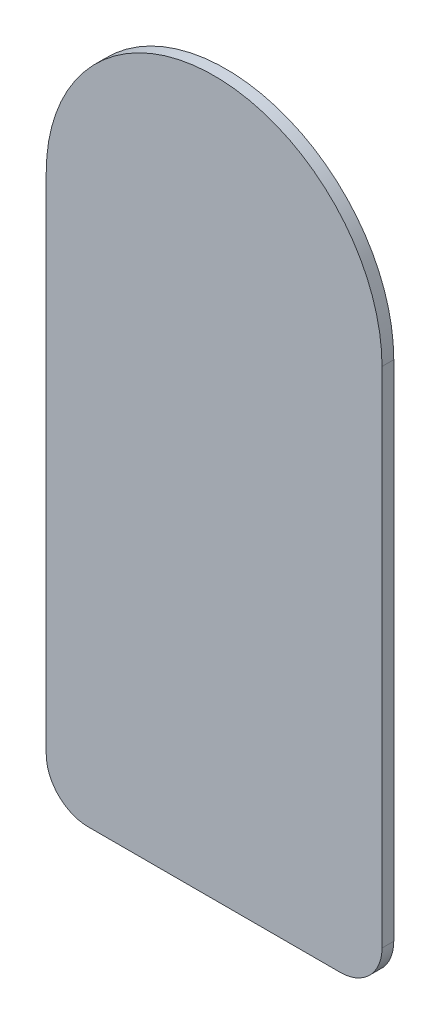
from build123d import *

# Parameters (mm, degrees)
BOSS_EXTRUDE1_DEPTH = 0.7112


with BuildPart() as part:
    # Sketch1 → Boss-Extrude1 (new body)
    with BuildSketch(Plane.XY):
        with BuildLine():
            Line((10.16, -30.48), (10.16, 0))
            ThreePointArc((10.16, 0), (0, 10.16), (-10.16, 0))
            Line((-10.16, 0), (-10.16, -30.48))
            ThreePointArc((-10.16, -30.48), (-9.416051224, -32.276051224), (-7.62, -33.02))
            Line((-7.62, -33.02), (7.62, -33.02))
            ThreePointArc((7.62, -33.02), (9.416051224, -32.276051224), (10.16, -30.48))
        make_face()
    extrude(amount=BOSS_EXTRUDE1_DEPTH)


solid = part.part
